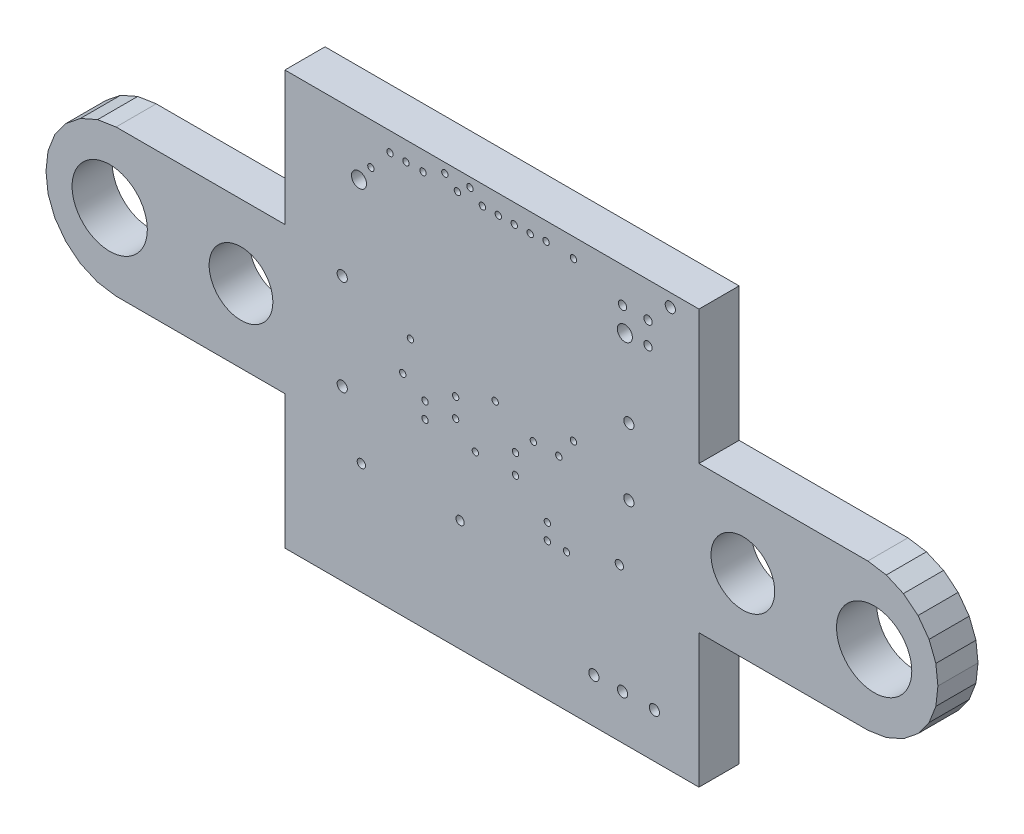
from build123d import *

# Parameters (mm, degrees)
BOARD_OUTLINE_DEPTH = 1.6
SKETCH2_R           = 0.3
SKETCH2_R_2         = 0.127
SKETCH2_R_3         = 0.1651
SKETCH2_R_4         = 0.2032
SKETCH2_R_5         = 1.5
NPTH_DEPTH          = 2.6
SKETCH3_R           = 1.27
PTH_DEPTH           = 2.6


with BuildPart() as part:
    # Sketch1 → Board_Outline (new body)
    with BuildSketch(Plane.XY):
        Polygon((0, 16.51), (0, 11.176), (-6.731, 11.176), (-7.468412, 11.062199), (-8.151243, 10.761418), (-8.732959, 10.294157), (-9.173918, 9.692258), (-9.444069, 8.996739), (-9.525, 8.255), (-9.444069, 7.513261), (-9.173918, 6.817742), (-8.732959, 6.215843), (-8.151243, 5.748582), (-7.468412, 5.447801), (-6.731, 5.334), (0, 5.334), (0, 0), (16.51, 0), (16.51, 5.334), (23.241, 5.334), (23.978412, 5.447801), (24.661243, 5.748582), (25.242959, 6.215843), (25.683918, 6.817742), (25.954069, 7.513261), (26.035, 8.255), (25.954069, 8.996739), (25.683918, 9.692258), (25.242959, 10.294157), (24.661243, 10.761418), (23.978412, 11.062199), (23.241, 11.176), (16.51, 11.176), (16.51, 16.51), align=None)
    extrude(amount=BOARD_OUTLINE_DEPTH)

    # Sketch2 → NPTH (cut, through all)
    with BuildSketch(Plane.XY):
        with Locations((13.555, 14.2)):
            Circle(SKETCH2_R)
        with Locations((2.955, 14.2)):
            Circle(SKETCH2_R)
        with Locations((9.1948, 7.8994)):
            Circle(SKETCH2_R_2)
        with Locations((10.4648, 5.4864)):
            Circle(SKETCH2_R_2)
        with Locations((11.2268, 5.4864)):
            Circle(SKETCH2_R_2)
        with Locations((10.4648, 6.1214)):
            Circle(SKETCH2_R_2)
        with Locations((10.414, 15.7988)):
            Circle(SKETCH2_R_2)
        with Locations((5.005, 9.727)):
            Circle(SKETCH2_R_2)
        with Locations((6.8072, 8.636)):
            Circle(SKETCH2_R_2)
        with Locations((4.699, 8.382)):
            Circle(SKETCH2_R_2)
        with Locations((10.922, 8.636)):
            Circle(SKETCH2_R_2)
        with Locations((6.378, 16.129)):
            Circle(SKETCH2_R_2)
        with Locations((6.8072, 7.874)):
            Circle(SKETCH2_R_2)
        with Locations((6.878, 15.748)):
            Circle(SKETCH2_R_2)
        with Locations((7.378, 16.141)):
            Circle(SKETCH2_R_2)
        with Locations((7.5946, 7.1186)):
            Circle(SKETCH2_R_2)
        with Locations((8.509, 15.748)):
            Circle(SKETCH2_R_2)
        with Locations((5.588, 7.239)):
            Circle(SKETCH2_R_2)
        with Locations((9.779, 15.748)):
            Circle(SKETCH2_R_2)
        with Locations((9.906, 8.636)):
            Circle(SKETCH2_R_2)
        with Locations((9.194, 7.112)):
            Circle(SKETCH2_R_2)
        with Locations((9.144, 15.748)):
            Circle(SKETCH2_R_2)
        with Locations((5.588, 7.874)):
            Circle(SKETCH2_R_2)
        with Locations((13.335, 6.096)):
            Circle(SKETCH2_R_3)
        with Locations((12.319, 1.778)):
            Circle(SKETCH2_R_4)
        with Locations((13.716, 8.509)):
            Circle(SKETCH2_R_4)
        with Locations((2.286, 6.731)):
            Circle(SKETCH2_R_4)
        with Locations((6.985, 4.445)):
            Circle(SKETCH2_R_3)
        with Locations((3.048, 4.445)):
            Circle(SKETCH2_R_3)
        with Locations((11.505, 9.45)):
            Circle(SKETCH2_R_2)
        with Locations((8.386, 9.267)):
            Circle(SKETCH2_R_2)
        with Locations((4.826, 15.748)):
            Circle(SKETCH2_R_2)
        with Locations((4.191, 15.748)):
            Circle(SKETCH2_R_2)
        with Locations((-6.985, 8.255)):
            Circle(SKETCH2_R_5)
        with Locations((23.495, 8.255)):
            Circle(SKETCH2_R_5)
        with Locations((13.716, 11.176)):
            Circle(SKETCH2_R_4)
        with Locations((2.286, 10.541)):
            Circle(SKETCH2_R_4)
        with Locations((14.478, 15.113)):
            Circle(SKETCH2_R_3)
        with Locations((13.462, 15.113)):
            Circle(SKETCH2_R_3)
        with Locations((14.478, 14.224)):
            Circle(SKETCH2_R_3)
        with Locations((5.505, 15.748)):
            Circle(SKETCH2_R_2)
        with Locations((3.429, 14.859)):
            Circle(SKETCH2_R_2)
        with Locations((7.874, 15.748)):
            Circle(SKETCH2_R_2)
        with Locations((11.5062, 15.748)):
            Circle(SKETCH2_R_2)
        with Locations((13.462, 1.778)):
            Circle(SKETCH2_R_4)
        with Locations((14.732, 1.778)):
            Circle(SKETCH2_R_4)
        with Locations((15.367, 16.002)):
            Circle(SKETCH2_R_4)
    extrude(amount=NPTH_DEPTH, mode=Mode.SUBTRACT)

    # Sketch3 → PTH (cut, through all)
    with BuildSketch(Plane.XY):
        with Locations((-1.75, 8.26)):
            Circle(SKETCH3_R)
        with Locations((18.26, 8.26)):
            Circle(SKETCH3_R)
    extrude(amount=PTH_DEPTH, mode=Mode.SUBTRACT)


solid = part.part
